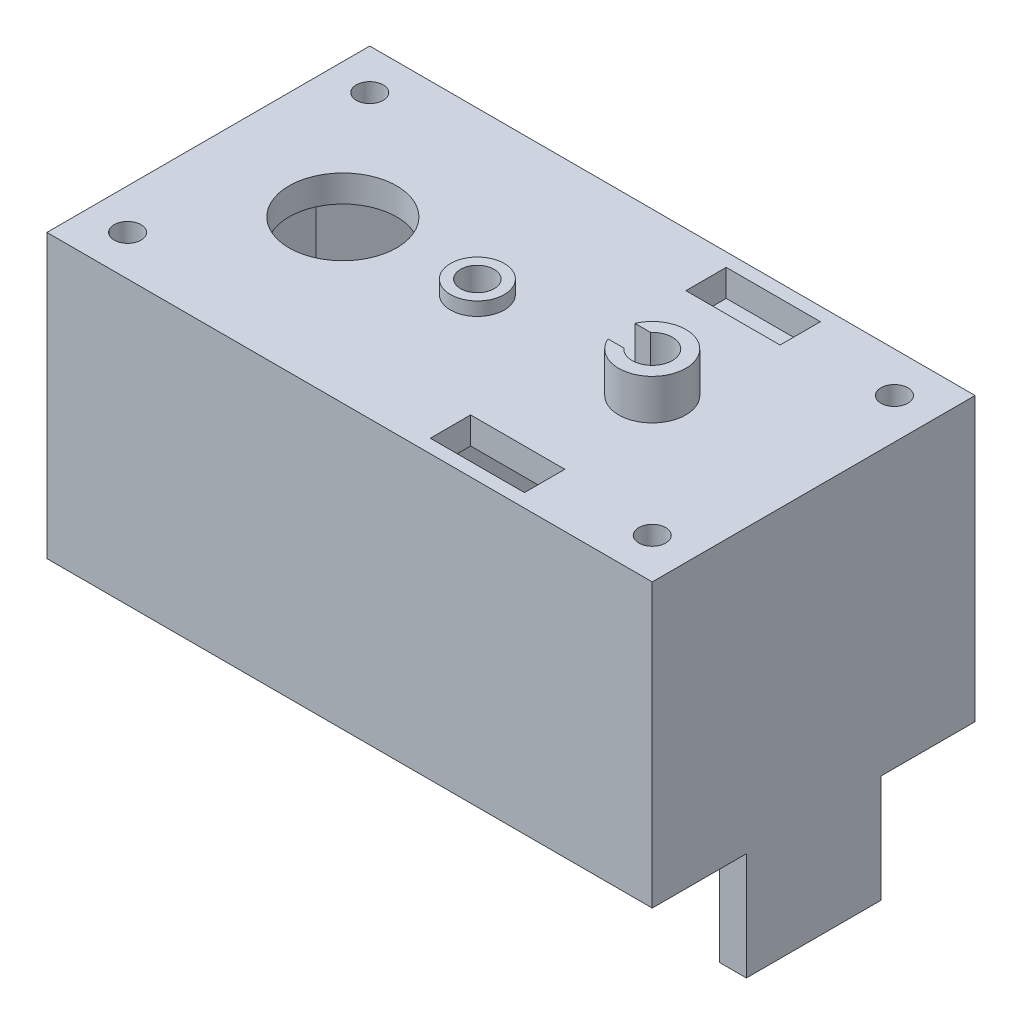
from build123d import *

# Parameters (mm, degrees)
SKETCH1_W           = 22.5
SKETCH1_H           = 12
SKETCH1_W_2         = 11.5
SKETCH1_H_2         = 10
SKETCH1_W_3         = 8
BOSS_EXTRUDE1_DEPTH = 10.5
SKETCH2_W           = 22.5
SKETCH2_H           = 12
SKETCH2_R           = 2
SKETCH2_R_2         = 0.75
SKETCH2_W_2         = 3.5
SKETCH2_H_2         = 1.5
BOSS_EXTRUDE2_DEPTH = 1
SKETCH3_W           = 3.5
SKETCH3_H           = 1.5
CUT_EXTRUDE1_DEPTH  = 1
SKETCH4_W           = 10
SKETCH4_H           = 2.5
CUT_EXTRUDE2_DEPTH  = 1
CHAMFER1_SIZE       = 2
SKETCH5_R           = 0.5
CUT_EXTRUDE3_DEPTH  = 11.5
SKETCH6_W           = 1
SKETCH6_H           = 5
BOSS_EXTRUDE3_DEPTH = 4
SKETCH7_R           = 1
SKETCH7_R_2         = 0.625
BOSS_EXTRUDE4_DEPTH = 1.75
SKETCH8_R           = 0.625
CUT_EXTRUDE4_DEPTH  = 1.75
SKETCH9_R           = 1
BOSS_EXTRUDE5_DEPTH = 0.25
SKETCH10_R          = 1
SKETCH10_R_2        = 0.625
BOSS_EXTRUDE6_DEPTH = 0.5
SKETCH11_R          = 1.25
SKETCH11_R_2        = 0.75
BOSS_EXTRUDE7_DEPTH = 1.5
CUT_EXTRUDE5_DEPTH  = 1.5


with BuildPart() as part:
    # Sketch1 → Boss-Extrude1 (new body)
    with BuildSketch(Plane(origin=(0, 0, 0), x_dir=(1, 0, 0), z_dir=(0, 1, 0))):
        Rectangle(SKETCH1_W, SKETCH1_H)
        with Locations((4.5, 0)):
            Rectangle(SKETCH1_W_2, SKETCH1_H_2, mode=Mode.SUBTRACT)
        with Locations((-6.25, 0)):
            Rectangle(SKETCH1_W_3, SKETCH1_H_2, mode=Mode.SUBTRACT)
    extrude(amount=BOSS_EXTRUDE1_DEPTH)

    # Sketch2 → Boss-Extrude2 (add)
    with BuildSketch(Plane(origin=(0, 10.5, 0), x_dir=(1, 0, 0), z_dir=(0, 1, 0))):
        Rectangle(SKETCH2_W, SKETCH2_H)
        with Locations((-6.25, 0)):
            Circle(SKETCH2_R, mode=Mode.SUBTRACT)
        with Locations((5.25, 0)):
            Circle(SKETCH2_R_2, mode=Mode.SUBTRACT)
        with Locations((4.25, 4.75)):
            Rectangle(SKETCH2_W_2, SKETCH2_H_2, mode=Mode.SUBTRACT)
        with Locations((4.25, -4.75)):
            Rectangle(SKETCH2_W_2, SKETCH2_H_2, mode=Mode.SUBTRACT)
    extrude(amount=-BOSS_EXTRUDE2_DEPTH)

    # Sketch3 → Cut-Extrude1 (cut)
    with BuildSketch(Plane(origin=(0, 10.5, 0), x_dir=(1, 0, 0), z_dir=(0, 1, 0))):
        with Locations((4.25, 4.75)):
            Rectangle(SKETCH3_W, SKETCH3_H)
        with Locations((4.25, -4.75)):
            Rectangle(SKETCH3_W, SKETCH3_H)
    extrude(amount=-CUT_EXTRUDE1_DEPTH, mode=Mode.SUBTRACT)

    # Sketch4 → Cut-Extrude2 (cut)
    with BuildSketch(Plane.ZY.offset(2.25)):
        with Locations((0, 1.25)):
            Rectangle(SKETCH4_W, SKETCH4_H)
    extrude(amount=-CUT_EXTRUDE2_DEPTH, mode=Mode.SUBTRACT)

    # Chamfer1
    chamfer1_edges = [part.edges().sort_by_distance(p)[0] for p in [
        (-10.25, 4.75, 5),
        (-10.25, 4.75, -5),
        (10.25, 4.75, -5),
        (10.25, 4.75, 5),
    ]]
    chamfer(chamfer1_edges, length=CHAMFER1_SIZE)

    # Sketch5 → Cut-Extrude3 (cut, through all)
    with BuildSketch(Plane.XZ):
        with Locations((-9.75, 4.5)):
            Circle(SKETCH5_R)
        with Locations((9.75, 4.5)):
            Circle(SKETCH5_R)
        with Locations((9.75, -4.5)):
            Circle(SKETCH5_R)
        with Locations((-9.75, -4.5)):
            Circle(SKETCH5_R)
    extrude(amount=-CUT_EXTRUDE3_DEPTH, mode=Mode.SUBTRACT)

    # Sketch6 → Boss-Extrude3 (add)
    with BuildSketch(Plane.XZ):
        with Locations((10.75, 0)):
            Rectangle(SKETCH6_W, SKETCH6_H)
    extrude(amount=BOSS_EXTRUDE3_DEPTH)

    # Sketch7 → Boss-Extrude4 (add)
    with BuildSketch(Plane(origin=(0, 10.5, 0), x_dir=(1, 0, 0), z_dir=(0, 1, 0))):
        with Locations((-1.25, 0)):
            Circle(SKETCH7_R)
        with Locations((-1.25, 0)):
            Circle(SKETCH7_R_2, mode=Mode.SUBTRACT)
    extrude(amount=-BOSS_EXTRUDE4_DEPTH)

    # Sketch8 → Cut-Extrude4 (cut)
    with BuildSketch(Plane(origin=(0, 10.5, 0), x_dir=(1, 0, 0), z_dir=(0, 1, 0))):
        with Locations((-1.25, 0)):
            Circle(SKETCH8_R)
    extrude(amount=-CUT_EXTRUDE4_DEPTH, mode=Mode.SUBTRACT)

    # Sketch9 → Boss-Extrude5 (add)
    with BuildSketch(Plane.XZ.offset(-8.75)):
        with Locations((-1.25, 0)):
            Circle(SKETCH9_R)
    extrude(amount=BOSS_EXTRUDE5_DEPTH)

    # Sketch10 → Boss-Extrude6 (add)
    with BuildSketch(Plane(origin=(0, 10.5, 0), x_dir=(1, 0, 0), z_dir=(0, 1, 0))):
        with Locations((-1.25, 0)):
            Circle(SKETCH10_R)
        with Locations((-1.25, 0)):
            Circle(SKETCH10_R_2, mode=Mode.SUBTRACT)
    extrude(amount=BOSS_EXTRUDE6_DEPTH)

    # Sketch11 → Boss-Extrude7 (add)
    with BuildSketch(Plane(origin=(0, 10.5, 0), x_dir=(1, 0, 0), z_dir=(0, 1, 0))):
        with Locations((5.25, 0)):
            Circle(SKETCH11_R)
        with Locations((5.25, 0)):
            Circle(SKETCH11_R_2, mode=Mode.SUBTRACT)
    extrude(amount=BOSS_EXTRUDE7_DEPTH)

    # Sketch12 → Cut-Extrude5 (cut)
    with BuildSketch(Plane(origin=(0, 12, 0), x_dir=(1, 0, 0), z_dir=(0, 1, 0))):
        with BuildLine():
            Line((4.104356076, 0.5), (4.690983006, 0.5))
            ThreePointArc((4.690983006, 0.5), (4.5, 0), (4.690983006, -0.5))
            Line((4.690983006, -0.5), (4.104356076, -0.5))
            ThreePointArc((4.104356076, -0.5), (4, 0), (4.104356076, 0.5))
        make_face()
    extrude(amount=-CUT_EXTRUDE5_DEPTH, mode=Mode.SUBTRACT)


solid = part.part
